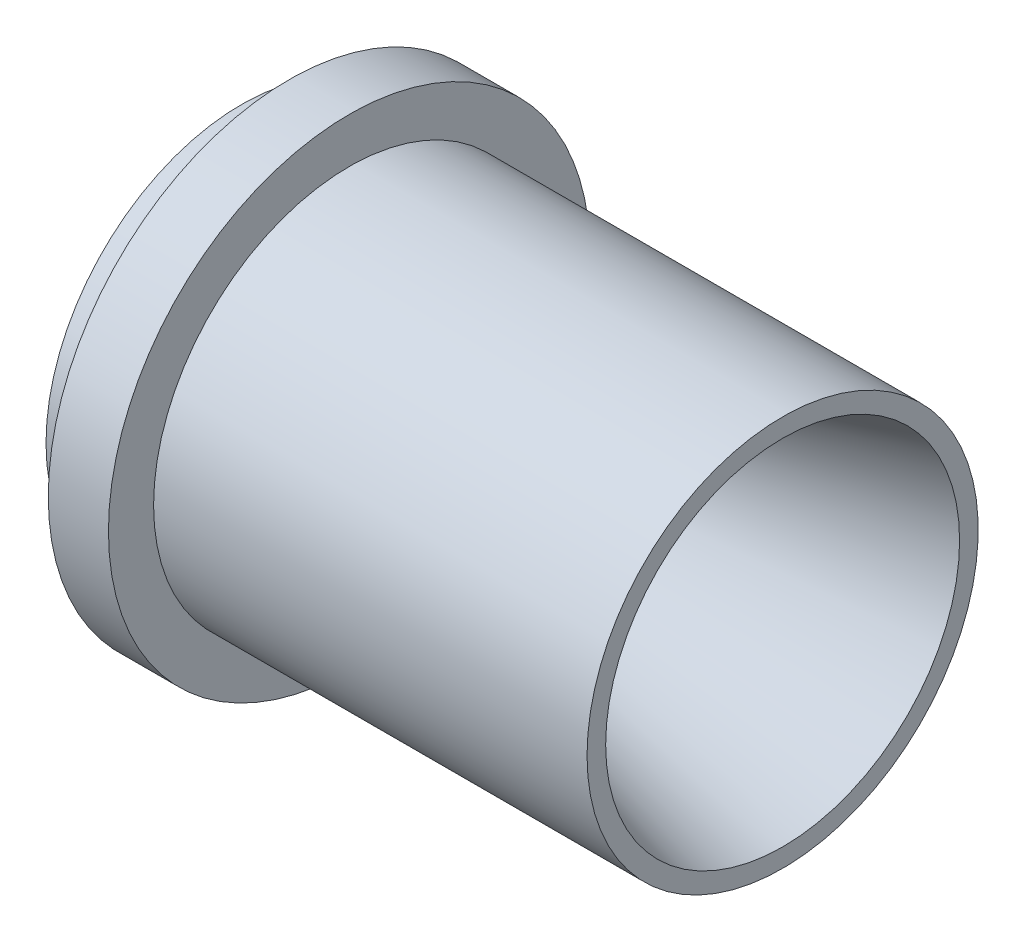
from build123d import *


with BuildPart() as part:
    # Sketch1 → Revolve1 (revolve)
    with BuildSketch(Plane.XY):
        with BuildLine():
            Line((-6.3, 26), (4.726601718, 14.973398282))
            ThreePointArc((4.726601718, 14.973398282), (11.450917759, 11.091112606), (19.215489112, 11.091112606))
            Line((19.215489112, 11.091112606), (65.619388603, 23.525))
            Line((65.619388603, 23.525), (65.619388603, 26))
            Line((65.619388603, 26), (8, 26))
            Line((8, 26), (8, 32))
            Line((8, 32), (0, 32))
            Line((0, 32), (0, 26))
            Line((0, 26), (-6.3, 26))
        make_face()
    revolve(axis=Axis((0, 0, 0), (1, 0, 0)))


solid = part.part
